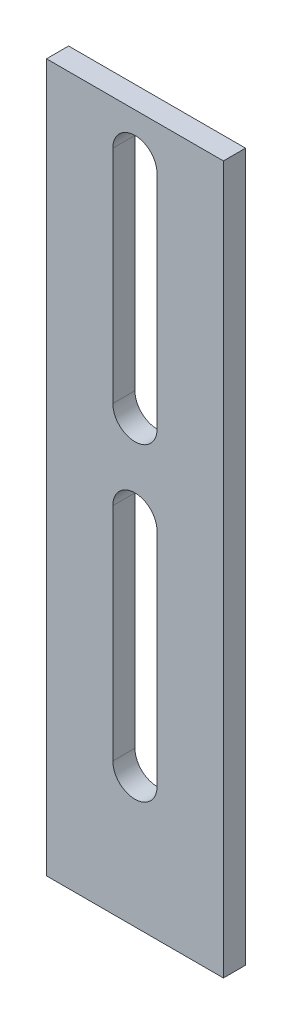
from build123d import *

# Parameters (mm, degrees)
SKETCH1_W           = 25.4
SKETCH1_H           = 101.6
SKETCH1_R           = 2.38125
BOSS_EXTRUDE1_DEPTH = 3.175
CUT_EXTRUDE1_DEPTH  = 4.175


with BuildPart() as part:
    # Sketch1 → Boss-Extrude1 (new body)
    with BuildSketch(Plane.XY):
        with Locations((0, -38.1)):
            Rectangle(SKETCH1_W, SKETCH1_H)
        with Locations((0, 6.35)):
            Circle(SKETCH1_R, mode=Mode.SUBTRACT)
        with Locations((0, -69.85)):
            Circle(SKETCH1_R, mode=Mode.SUBTRACT)
    extrude(amount=BOSS_EXTRUDE1_DEPTH)

    # Sketch2 → Cut-Extrude1 (cut, through all)
    with BuildSketch(Plane.XY.offset(3.175)):
        with BuildLine():
            Line((-3.175, -25.4), (-3.175, 6.35))
            ThreePointArc((-3.175, 6.35), (0, 9.525), (3.175, 6.35))
            Line((3.175, 6.35), (3.175, -25.4))
            ThreePointArc((3.175, -25.4), (0, -28.575), (-3.175, -25.4))
        make_face()
        with BuildLine():
            Line((-3.175, -69.85), (-3.175, -38.1))
            ThreePointArc((-3.175, -38.1), (0, -34.925), (3.175, -38.1))
            Line((3.175, -38.1), (3.175, -69.85))
            ThreePointArc((3.175, -69.85), (0, -73.025), (-3.175, -69.85))
        make_face()
    extrude(amount=-CUT_EXTRUDE1_DEPTH, mode=Mode.SUBTRACT)


solid = part.part
